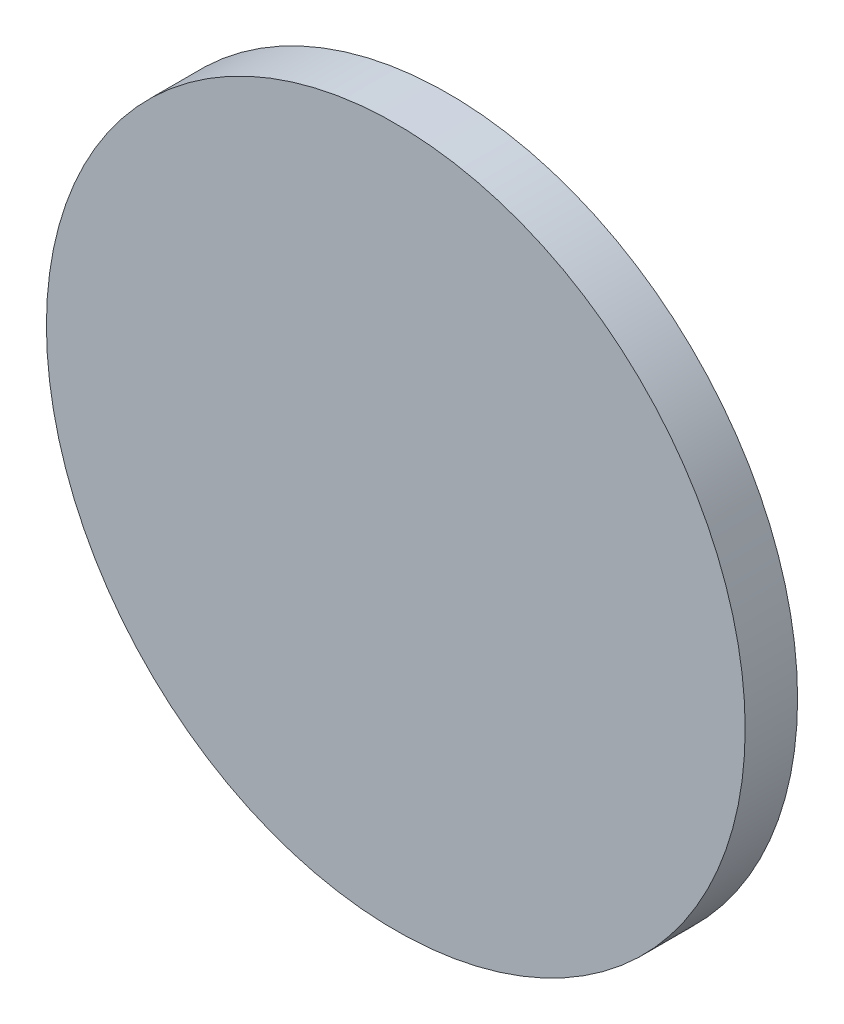
from build123d import *

# Parameters (mm, degrees)
SKETCH_1_R      = 20
EXTRUDE_1_DEPTH = 3


with BuildPart() as part:
    # 草图1 → 凸台-拉伸1 (new body)
    with BuildSketch(Plane.XY):
        Circle(SKETCH_1_R)
    extrude(amount=EXTRUDE_1_DEPTH)


solid = part.part
